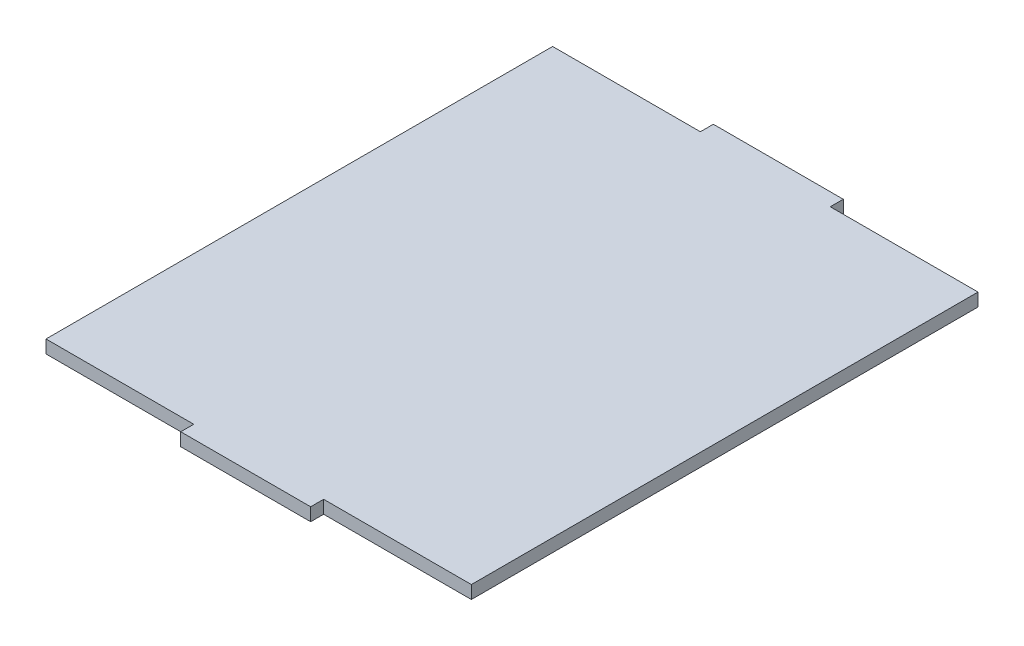
from build123d import *

# Parameters (mm, degrees)
BOSS_EXTRUDE1_DEPTH = 3


with BuildPart() as part:
    # Sketch1 → Boss-Extrude1 (new body)
    with BuildSketch(Plane(origin=(0, 0, 0), x_dir=(1, 0, 0), z_dir=(0, 1, 0))):
        Polygon((-60.502378178, 76.308313029), (-26.387378178, 76.308313029), (-26.387378178, 79.308313029), (3.612621822, 79.308313029), (3.612621822, 76.308313029), (37.727621822, 76.308313029), (37.727621822, -40.691686971), (3.612621822, -40.691686971), (3.612621822, -43.691686971), (-26.387378178, -43.691686971), (-26.387378178, -40.691686971), (-60.502378178, -40.691686971), align=None)
    extrude(amount=BOSS_EXTRUDE1_DEPTH)


solid = part.part
